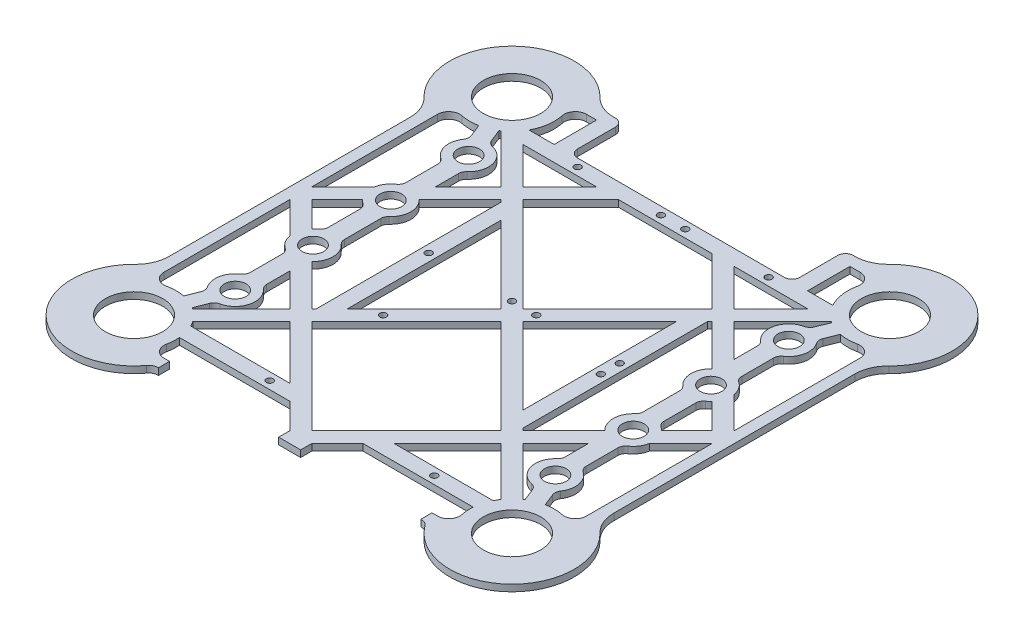
from build123d import *

# Parameters (mm, degrees)
SKETCH1_R           = 12.9
SKETCH1_R_2         = 1.5
BOSS_EXTRUDE1_DEPTH = 3
SKETCH3_R           = 4.9
BOSS_EXTRUDE2_DEPTH = 3
SKETCH5_R           = 4.9
CUT_EXTRUDE2_DEPTH  = 3
SKETCH6_R           = 1.5
CUT_EXTRUDE3_DEPTH  = 3


with BuildPart() as part:
    # Sketch1 → Boss-Extrude1 (new body)
    with BuildSketch(Plane(origin=(0, 0, 0), x_dir=(1, 0, 0), z_dir=(0, 1, 0))):
        with BuildLine():
            Line((100, 54.19416698), (100, -54.194145817))
            ThreePointArc((100, -54.194145817), (101.180145728, -60.026094712), (104.534883721, -64.940370329))
            ThreePointArc((104.534883721, -64.940370329), (103.485393769, -106.03068644), (62.599986177, -101.799970988))
            ThreePointArc((62.599986177, -101.799970988), (61.029650699, -100.440662043), (59, -99.999989419))
            Line((59, -99.999989419), (59, -94.999989419))
            Line((59, -94.999989419), (61.526610811, -94.999989419))
            ThreePointArc((61.526610811, -94.999989419), (65.41301875, -93.145753767), (66.416900226, -88.958322752))
            ThreePointArc((66.416900226, -88.958322752), (66.040643988, -86.242092323), (66.059303075, -83.499989419))
            Line((66.059303075, -83.499989419), (16.449762223, -83.499989419))
            Line((16.449762223, -83.499989419), (4.949763655, -94.999989419))
            Line((4.949763655, -94.999989419), (4.949763655, -99.999989419))
            Line((4.949763655, -99.999989419), (0, -99.999989419))
            Line((0, -99.999989419), (0, -90.050258137))
            Line((0, -90.050258137), (42.550255488, -47.499997352))
            Line((42.550255488, -47.499997352), (0, -4.94974716))
            Line((0, -4.94974716), (0, 4.949747776))
            Line((0, 4.949747776), (42.550249575, 47.500002648))
            Line((42.550249575, 47.500002648), (21.090238971, 68.960010581))
            Line((21.090238971, 68.960010581), (0, 68.960010581))
            Line((0, 68.960010581), (0, 75.960010581))
            Line((0, 75.960010581), (46.5, 75.960010581))
            ThreePointArc((46.5, 75.960010581), (48.974873734, 76.985136847), (50, 79.460010581))
            Line((50, 79.460010581), (50, 96.500010581))
            ThreePointArc((50, 96.500010581), (51.025126266, 98.974884315), (53.5, 100.000010581))
            Line((53.5, 100.000010581), (54.194156399, 100.000010581))
            ThreePointArc((54.194156399, 100.000010581), (60.026105293, 101.18015631), (64.940380911, 104.534894302))
            ThreePointArc((64.940380911, 104.534894302), (104.798989873, 104.799000455), (104.534883721, 64.940391492))
            ThreePointArc((104.534883721, 64.940391492), (101.180145728, 60.026115874), (100, 54.19416698))
        make_face()
        with Locations((85, 85.000010581)):
            Circle(SKETCH1_R, mode=Mode.SUBTRACT)
        with Locations((85, -84.999989419)):
            Circle(SKETCH1_R, mode=Mode.SUBTRACT)
        with Locations((5.460009902, 5.460010581)):
            Circle(SKETCH1_R_2, mode=Mode.SUBTRACT)
        with Locations((5.460009902, 72.460010581)):
            Circle(SKETCH1_R_2, mode=Mode.SUBTRACT)
        with Locations((42.960009902, 5.460010581)):
            Circle(SKETCH1_R_2, mode=Mode.SUBTRACT)
        with Locations((42.960009902, 72.460010581)):
            Circle(SKETCH1_R_2, mode=Mode.SUBTRACT)
        Polygon((47.500007317, 52.449761006), (64.010254837, 68.960010581), (30.989755686, 68.960010581), align=None, mode=Mode.SUBTRACT)
        Polygon((4.949747468, 3.08e-07), (39.460009902, -34.510257829), (39.460009902, 34.510267037), align=None, mode=Mode.SUBTRACT)
        with BuildLine():
            Line((57, 95.000010581), (61.526610811, 95.000010581))
            ThreePointArc((61.526610811, 95.000010581), (65.41301875, 93.145774929), (66.416900226, 88.958343915))
            ThreePointArc((66.416900226, 88.958343915), (66.193922226, 82.292347609), (68.288375303, 75.960010581))
            Line((68.288375303, 75.960010581), (57, 75.960010581))
            Line((57, 75.960010581), (57, 95.000010581))
        make_face(mode=Mode.SUBTRACT)
        with BuildLine():
            Line((95, 61.526621393), (95, 4.949774236))
            Line((95, 4.949774236), (52.449755093, 47.500013846))
            Line((52.449755093, 47.500013846), (74.269762064, 69.320023533))
            ThreePointArc((74.269762064, 69.320023533), (81.316022684, 66.360581643), (88.958333333, 66.416910807))
            ThreePointArc((88.958333333, 66.416910807), (93.145764348, 65.413029331), (95, 61.526621393))
        make_face(mode=Mode.SUBTRACT)
        with BuildLine():
            Line((95, -4.949741863), (52.449750425, -47.499996735))
            Line((52.449750425, -47.499996735), (74.269760112, -69.320003706))
            ThreePointArc((74.269760112, -69.320003706), (81.316021524, -66.36056071), (88.958333333, -66.416889644))
            ThreePointArc((88.958333333, -66.416889644), (93.145764348, -65.413008169), (95, -61.52660023))
            Line((95, -61.52660023), (95, -4.949741863))
        make_face(mode=Mode.SUBTRACT)
        with BuildLine():
            Line((47.500003265, -52.449744512), (69.320012952, -74.269751483))
            ThreePointArc((69.320012952, -74.269751483), (68.625668893, -75.362495927), (68.007354532, -76.499989419))
            Line((68.007354532, -76.499989419), (23.449761352, -76.499989419))
            Line((23.449761352, -76.499989419), (47.500003265, -52.449744512))
        make_face(mode=Mode.SUBTRACT)
        Polygon((47.500002648, -42.550249575), (90.050252532, 5.605e-06), (47.499997352, 42.550255488), (46.460009902, 41.510267909), (46.460009902, -41.510256958), align=None, mode=Mode.SUBTRACT)
    boss_extrude1 = extrude(amount=BOSS_EXTRUDE1_DEPTH)

    # Sketch3 → Boss-Extrude2 (add)
    with BuildSketch(Plane(origin=(0, 0, 0), x_dir=(1, 0, 0), z_dir=(0, 1, 0))):
        with BuildLine():
            Line((81.318759719, -66.36001973), (79.103345611, -60.81738336))
            ThreePointArc((79.103345611, -60.81738336), (78.873720449, -59.141239523), (79.457102144, -57.55320562))
            ThreePointArc((79.457102144, -57.55320562), (80.847443498, -50.79914929), (77.049618943, -45.043555955))
            ThreePointArc((77.049618943, -45.043555955), (75.91850264, -43.785477346), (75.509618943, -42.14383183))
            Line((75.509618943, -42.14383183), (75.509618943, -27.856147007))
            ThreePointArc((75.509618943, -27.856147007), (75.91850264, -26.214501491), (77.049618943, -24.956422882))
            ThreePointArc((77.049618943, -24.956422882), (81.009618943, -17.499989419), (77.049618943, -10.043555955))
            ThreePointArc((77.049618943, -10.043555955), (75.91850264, -8.785477346), (75.509618943, -7.14383183))
            Line((75.509618943, -7.14383183), (75.509618943, 7.143852993))
            ThreePointArc((75.509618943, 7.143852993), (75.91850264, 8.785498509), (77.049618943, 10.043577118))
            ThreePointArc((77.049618943, 10.043577118), (81.009618943, 17.500010581), (77.049618943, 24.956444045))
            ThreePointArc((77.049618943, 24.956444045), (75.91850264, 26.214522654), (75.509618943, 27.85616817))
            Line((75.509618943, 27.85616817), (75.509618943, 42.143852993))
            ThreePointArc((75.509618943, 42.143852993), (75.91850264, 43.785498509), (77.049618943, 45.043577118))
            ThreePointArc((77.049618943, 45.043577118), (80.847443498, 50.799170453), (79.457102144, 57.553226783))
            ThreePointArc((79.457102144, 57.553226783), (78.873720449, 59.141260685), (79.103345611, 60.817404522))
            Line((79.103345611, 60.817404522), (81.318759719, 66.360040893))
            ThreePointArc((81.318759719, 66.360040893), (77.948078855, 67.357153438), (74.818759719, 68.958117104))
            Line((74.818759719, 68.958117104), (72.603345611, 63.415480734))
            ThreePointArc((72.603345611, 63.415480734), (71.614365012, 62.042854327), (70.097102144, 61.294456527))
            ThreePointArc((70.097102144, 61.294456527), (63.307032038, 54.794565258), (66.009618943, 45.791806649))
            ThreePointArc((66.009618943, 45.791806649), (66.871333862, 44.611929692), (67.17628561, 43.183060675))
            Line((67.17628561, 43.183060675), (67.17628561, 26.816960488))
            ThreePointArc((67.17628561, 26.816960488), (66.871333862, 25.388091471), (66.009618943, 24.208214514))
            ThreePointArc((66.009618943, 24.208214514), (63.009618943, 17.500010581), (66.009618943, 10.791806649))
            ThreePointArc((66.009618943, 10.791806649), (66.871333862, 9.611929692), (67.17628561, 8.183060675))
            Line((67.17628561, 8.183060675), (67.17628561, -8.183039512))
            ThreePointArc((67.17628561, -8.183039512), (66.871333862, -9.611908529), (66.009618943, -10.791785486))
            ThreePointArc((66.009618943, -10.791785486), (63.009618943, -17.499989419), (66.009618943, -24.208193351))
            ThreePointArc((66.009618943, -24.208193351), (66.871333862, -25.388070308), (67.17628561, -26.816939325))
            Line((67.17628561, -26.816939325), (67.17628561, -43.183039512))
            ThreePointArc((67.17628561, -43.183039512), (66.871333862, -44.611908529), (66.009618943, -45.791785486))
            ThreePointArc((66.009618943, -45.791785486), (63.307032038, -54.794544095), (70.097102144, -61.294435364))
            ThreePointArc((70.097102144, -61.294435364), (71.614365012, -62.042833164), (72.603345611, -63.415459571))
            Line((72.603345611, -63.415459571), (74.818759719, -68.958095941))
            ThreePointArc((74.818759719, -68.958095941), (77.948078855, -67.357132276), (81.318759719, -66.36001973))
        make_face()
        with Locations((72.009618943, 17.500010581)):
            Circle(SKETCH3_R, mode=Mode.SUBTRACT)
        with Locations((72.009618943, -17.499989419)):
            Circle(SKETCH3_R, mode=Mode.SUBTRACT)
        with Locations((72.009618943, -52.499989419)):
            Circle(SKETCH3_R, mode=Mode.SUBTRACT)
        with Locations((72.009618943, 52.500010581)):
            Circle(SKETCH3_R, mode=Mode.SUBTRACT)
    boss_extrude2 = extrude(amount=BOSS_EXTRUDE2_DEPTH)

    # Sketch5 → Cut-Extrude2 (cut)
    with BuildSketch(Plane(origin=(0, 0, 0), x_dir=(1, 0, 0), z_dir=(0, 1, 0))):
        with Locations((72.009618943, 17.500010581)):
            Circle(SKETCH5_R)
        with Locations((72.009618943, -17.499989419)):
            Circle(SKETCH5_R)
    cut_extrude2 = extrude(amount=CUT_EXTRUDE2_DEPTH, mode=Mode.SUBTRACT)

    # Mirror2: Boss-Extrude1, Boss-Extrude2, Cut-Extrude2 across plane
    add(boss_extrude1.mirror(Plane(origin=(0, 0, 0), x_dir=(0, 0, 1), z_dir=(1, 0, 0))))
    add(boss_extrude2.mirror(Plane(origin=(0, 0, 0), x_dir=(0, 0, 1), z_dir=(1, 0, 0))))
    add(cut_extrude2.mirror(Plane(origin=(0, 0, 0), x_dir=(0, 0, 1), z_dir=(1, 0, 0))), mode=Mode.SUBTRACT)

    # Sketch6 → Cut-Extrude3 (cut)
    with BuildSketch(Plane(origin=(0, 3, 0), x_dir=(1, 0, 0), z_dir=(0, 1, 0))):
        with Locations((45.013849476, -79.986146916)):
            Circle(SKETCH6_R)
        with Locations((42.960009902, -2.986146916)):
            Circle(SKETCH6_R)
        with Locations((-28.986150524, -79.986146916)):
            Circle(SKETCH6_R)
        with Locations((-28.986150524, -28.986146916)):
            Circle(SKETCH6_R)
    extrude(amount=-CUT_EXTRUDE3_DEPTH, mode=Mode.SUBTRACT)


solid = part.part
